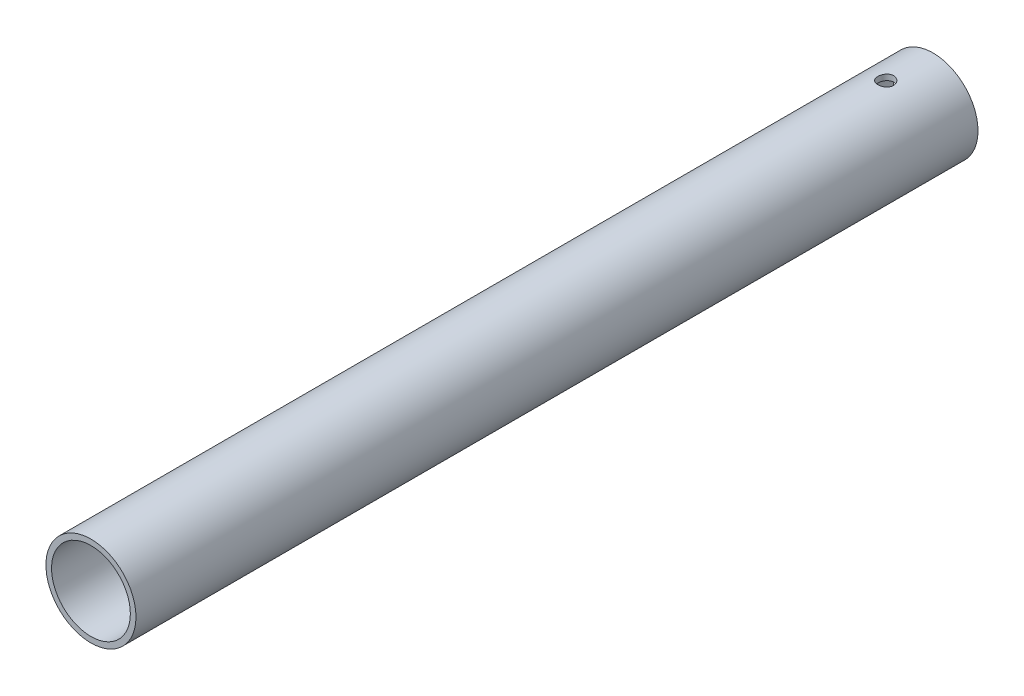
from build123d import *

# Parameters (mm, degrees)
SKETCH_1_R               = 8
SKETCH_1_R_2             = 7
EXTRUDE_1_DEPTH          = 149.6
SKETCH_2_R               = 1.4
CUT_EXTRUDE_1_DEPTH      = 9
CUT_EXTRUDE_1_DEPTH_BACK = 9


with BuildPart() as part:
    # 草圖1 → 填料-伸長1 (new body)
    with BuildSketch(Plane.XY):
        Circle(SKETCH_1_R)
        Circle(SKETCH_1_R_2, mode=Mode.SUBTRACT)
    extrude(amount=EXTRUDE_1_DEPTH)

    # 草圖2 → 除料-伸長1 (cut, two sides)
    with BuildSketch(Plane(origin=(0, 0, 0), x_dir=(1, 0, 0), z_dir=(0, 1, 0))) as cut_extrude_1_sk:
        with Locations((0, -8.4)):
            Circle(SKETCH_2_R)
    extrude(amount=CUT_EXTRUDE_1_DEPTH, mode=Mode.SUBTRACT)
    extrude(cut_extrude_1_sk.sketch, amount=-CUT_EXTRUDE_1_DEPTH_BACK, mode=Mode.SUBTRACT)


solid = part.part
